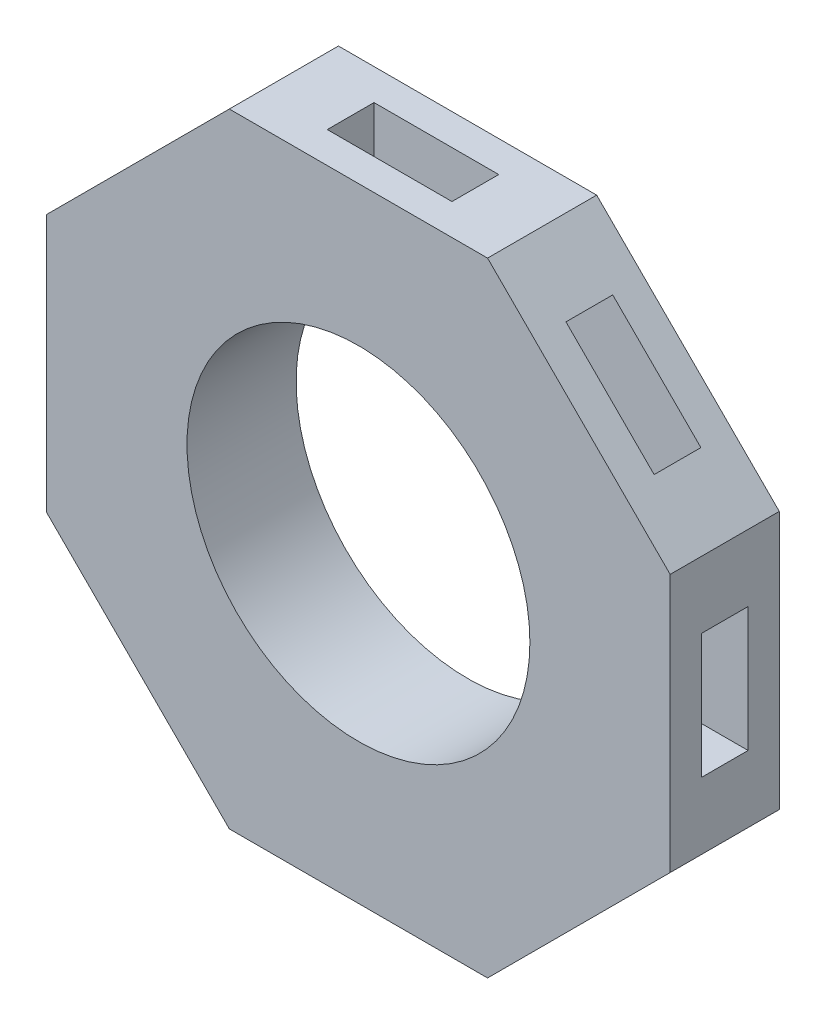
from build123d import *

# Parameters (mm, degrees)
SKETCH1_R               = 11
BOSS_EXTRUDE1_DEPTH     = 3.5
CUT_EXTRUDE3_REACH      = 46.858
CUT_EXTRUDE3_END_RADIUS = 13
SKETCH2_W               = 8
SKETCH2_H               = 3
CIRPATTERN1_COUNT       = 8


with BuildPart() as part:
    # Sketch1 → Boss-Extrude1 (new, symmetric)
    with BuildSketch(Plane.XY):
        Polygon((8.284271247, 20), (-8.284271247, 20), (-20, 8.284271247), (-20, -8.284271247), (-8.284271247, -20), (8.284271247, -20), (20, -8.284271247), (20, 8.284271247), align=None)
        Circle(SKETCH1_R, mode=Mode.SUBTRACT)
    extrude(amount=BOSS_EXTRUDE1_DEPTH, both=True)

    # Cut-Extrude3: up to this cylinder (the profile starts outside it)
    cut_extrude3_end = Plane(origin=(0, 0, 0), z_dir=(0, 0, -1)) * Cylinder(CUT_EXTRUDE3_END_RADIUS, 120.716, mode=Mode.PRIVATE)
    # Sketch2 → Cut-Extrude3 (cut, up to the surface)
    with BuildSketch(Plane(origin=(0, -20, 0), x_dir=(-1, 0, 0), z_dir=(0, -1, 0)), mode=Mode.PRIVATE) as cut_extrude3_sk1:
        Rectangle(SKETCH2_W, SKETCH2_H)
    cut_extrude3_tool1 = extrude(cut_extrude3_sk1.sketch, amount=-CUT_EXTRUDE3_REACH, mode=Mode.PRIVATE) - cut_extrude3_end
    cut_extrude3 = cut_extrude3_tool1.solids().sort_by_distance((0, -20, 0))[0]
    add(cut_extrude3, mode=Mode.SUBTRACT)

    # CirPattern1: Cut-Extrude3 ×8 about axis
    cirpattern1_axis = Axis((0, 0, 0), (0, 0, 1))
    for i in range(1, CIRPATTERN1_COUNT):
        add(cut_extrude3.rotate(cirpattern1_axis, i * 360 / CIRPATTERN1_COUNT), mode=Mode.SUBTRACT)


solid = part.part
